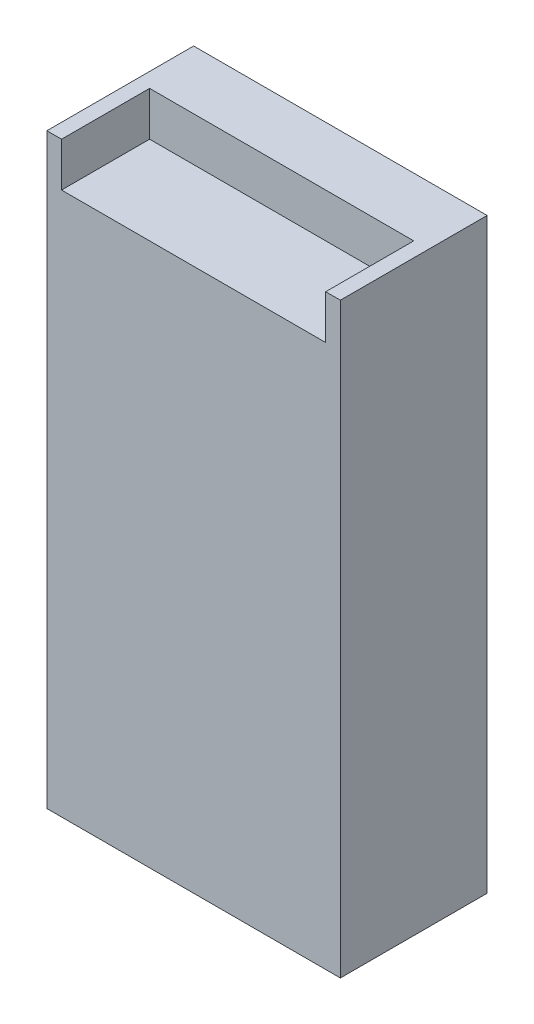
from build123d import *

# Parameters (mm, degrees)
SKETCH1_W           = 100
SKETCH1_H           = 200
BOSS_EXTRUDE1_DEPTH = 50
SKETCH2_W           = 90
SKETCH2_H           = 15
CUT_EXTRUDE1_DEPTH  = 30


with BuildPart() as part:
    # Sketch1 → Boss-Extrude1 (new body)
    with BuildSketch(Plane.XY):
        with Locations((50, 100)):
            Rectangle(SKETCH1_W, SKETCH1_H)
    extrude(amount=BOSS_EXTRUDE1_DEPTH)

    # Sketch2 → Cut-Extrude1 (cut)
    with BuildSketch(Plane.XY.offset(50)):
        with Locations((50, 192.5)):
            Rectangle(SKETCH2_W, SKETCH2_H)
    extrude(amount=-CUT_EXTRUDE1_DEPTH, mode=Mode.SUBTRACT)


solid = part.part
